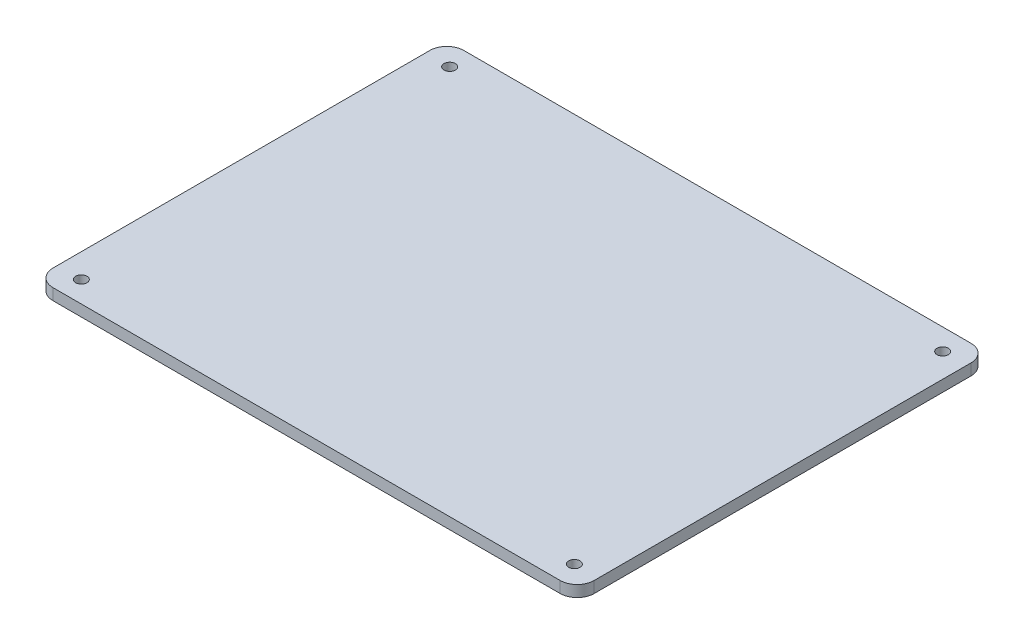
from build123d import *

# Parameters (mm, degrees)
EXTRUDE_1_DEPTH          = 2
SKETCH_3_R               = 1
CUT_EXTRUDE_1_DEPTH      = 3
CUT_EXTRUDE_1_DEPTH_BACK = 13
SKETCH_4_W               = 34
SKETCH_4_H               = 22
EXTRUDE_3_DEPTH          = 3
SKETCH_5_W               = 2
SKETCH_5_H               = 22
CUT_EXTRUDE_3_DEPTH      = 1.5


with BuildPart() as part:
    # Эскиз1 → Бобышка-Вытянуть1 (new body)
    with BuildSketch(Plane(origin=(0, 0, 0), x_dir=(1, 0, 0), z_dir=(0, 1, 0))):
        with BuildLine():
            Line((-47.75, -33.25), (-47.75, 33.25))
            ThreePointArc((-47.75, 33.25), (-46.871320344, 35.371320344), (-44.75, 36.25))
            Line((-44.75, 36.25), (44.75, 36.25))
            ThreePointArc((44.75, 36.25), (46.871320344, 35.371320344), (47.75, 33.25))
            Line((47.75, 33.25), (47.75, -33.25))
            ThreePointArc((47.75, -33.25), (46.871320344, -35.371320344), (44.75, -36.25))
            Line((44.75, -36.25), (-44.75, -36.25))
            ThreePointArc((-44.75, -36.25), (-46.871320344, -35.371320344), (-47.75, -33.25))
        make_face()
    extrude(amount=EXTRUDE_1_DEPTH)

    # Эскиз3 → Вырез-Вытянуть1 (cut, two sides)
    with BuildSketch(Plane(origin=(0, 5, 0), x_dir=(1, 0, 0), z_dir=(0, 1, 0))) as cut_extrude_1_sk:
        with Locations((-43.5, 32.5)):
            Circle(SKETCH_3_R)
        with Locations((-43.5, -32.5)):
            Circle(SKETCH_3_R)
        with Locations((43.5, -32.5)):
            Circle(SKETCH_3_R)
        with Locations((43.5, 32.5)):
            Circle(SKETCH_3_R)
    extrude(amount=CUT_EXTRUDE_1_DEPTH, mode=Mode.SUBTRACT)
    extrude(cut_extrude_1_sk.sketch, amount=-CUT_EXTRUDE_1_DEPTH_BACK, mode=Mode.SUBTRACT)

    # Эскиз4 → Бобышка-Вытянуть3 (add)
    with BuildSketch(Plane.XZ):
        Rectangle(SKETCH_4_W, SKETCH_4_H)
    extrude(amount=EXTRUDE_3_DEPTH)

    # Эскиз5 → Вырез-Вытянуть3 (cut)
    with BuildSketch(Plane.XZ):
        with Locations((-16, 0)):
            Rectangle(SKETCH_5_W, SKETCH_5_H)
        with Locations((16, 0)):
            Rectangle(SKETCH_5_W, SKETCH_5_H)
    extrude(amount=CUT_EXTRUDE_3_DEPTH, mode=Mode.SUBTRACT)


solid = part.part
